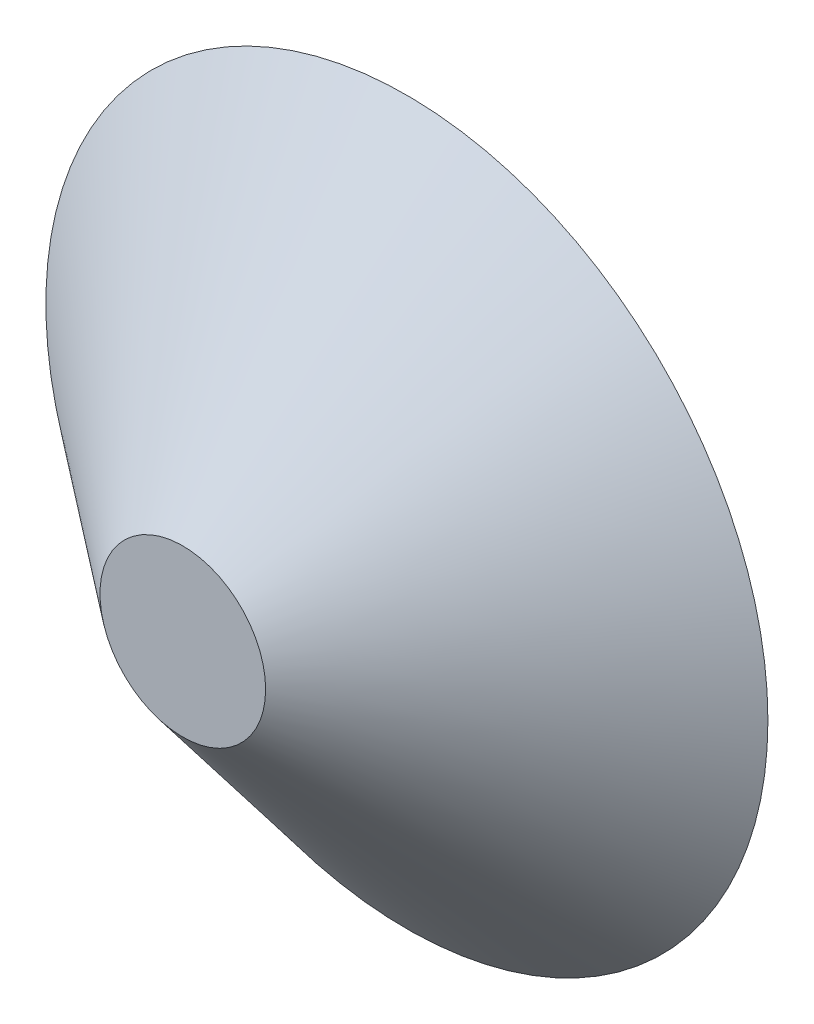
from build123d import *

# Parameters (mm, degrees)
SKETCH1_R           = 82.96975
BOSS_EXTRUDE4_DEPTH = 51.5
BOSS_EXTRUDE4_TAPER = 51.15


with BuildPart() as part:
    # Sketch1 → Boss-Extrude4 (new body)
    with BuildSketch(Plane.XY):
        Circle(SKETCH1_R)
    extrude(amount=BOSS_EXTRUDE4_DEPTH, taper=BOSS_EXTRUDE4_TAPER)


solid = part.part
